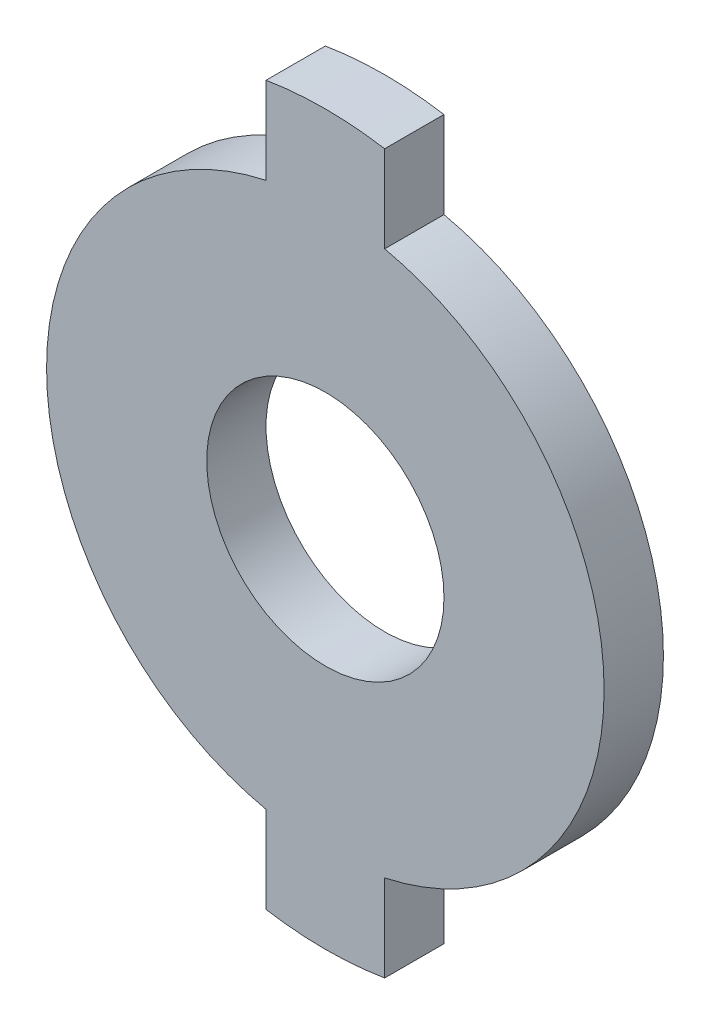
from build123d import *

# Parameters (mm, degrees)
BOSS_EXTRUDE1_DEPTH = 5
SKETCH2_R           = 10
CUT_EXTRUDE1_DEPTH  = 5


with BuildPart() as part:
    # Sketch1 → Boss-Extrude1 (new body)
    with BuildSketch(Plane.XY):
        with BuildLine():
            Line((-5, -22.961925006), (-5, -30.26982656))
            ThreePointArc((-5, -30.26982656), (0, -30.68), (5, -30.26982656))
            Line((5, -30.26982656), (5, -22.961925006))
            ThreePointArc((5, -22.961925006), (23.5, 0), (5, 22.961925006))
            Line((5, 22.961925006), (5, 30.26982656))
            ThreePointArc((5, 30.26982656), (0, 30.68), (-5, 30.26982656))
            Line((-5, 30.26982656), (-5, 22.961925006))
            ThreePointArc((-5, 22.961925006), (-23.5, 0), (-5, -22.961925006))
        make_face()
    extrude(amount=BOSS_EXTRUDE1_DEPTH)

    # Sketch2 → Cut-Extrude1 (cut)
    with BuildSketch(Plane.XY.offset(5)):
        Circle(SKETCH2_R)
    extrude(amount=-CUT_EXTRUDE1_DEPTH, mode=Mode.SUBTRACT)


solid = part.part
